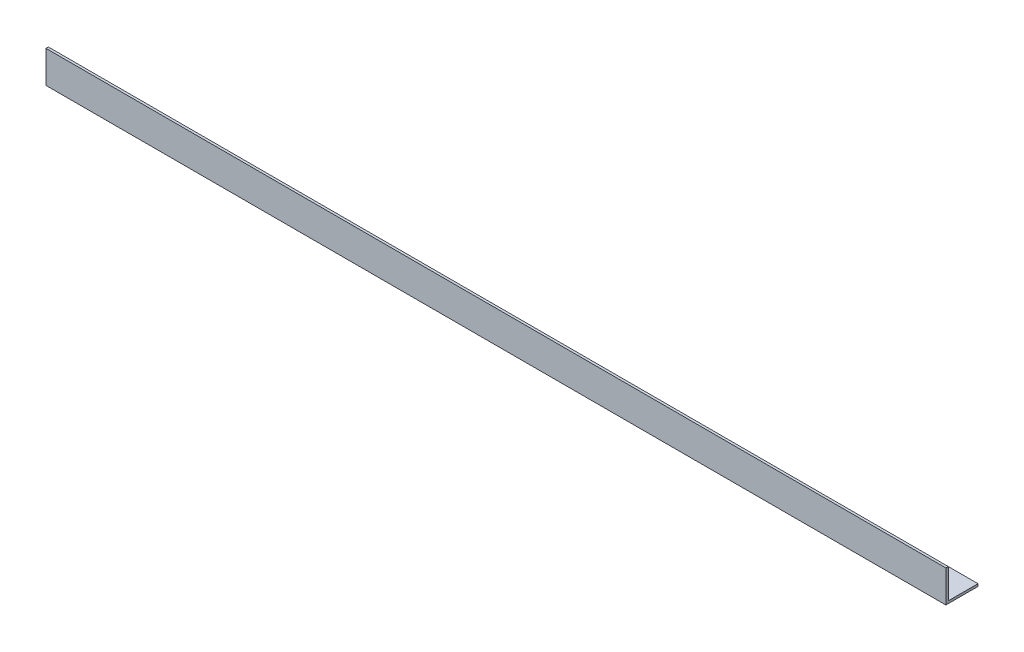
from build123d import *

# Parameters (mm, degrees)
EXTRUDE_1_DEPTH = 1120


with BuildPart() as part:
    # Эскиз1 → Вытянуть-Тонкостенный1 (new body)
    with BuildSketch(Plane(origin=(0, 0, 0), x_dir=(0, 0, -1), z_dir=(1, 0, 0))):
        Polygon((40, 0), (0, 0), (0, 40), (3, 40), (3, 3), (40, 3), align=None)
    extrude(amount=EXTRUDE_1_DEPTH)


solid = part.part
